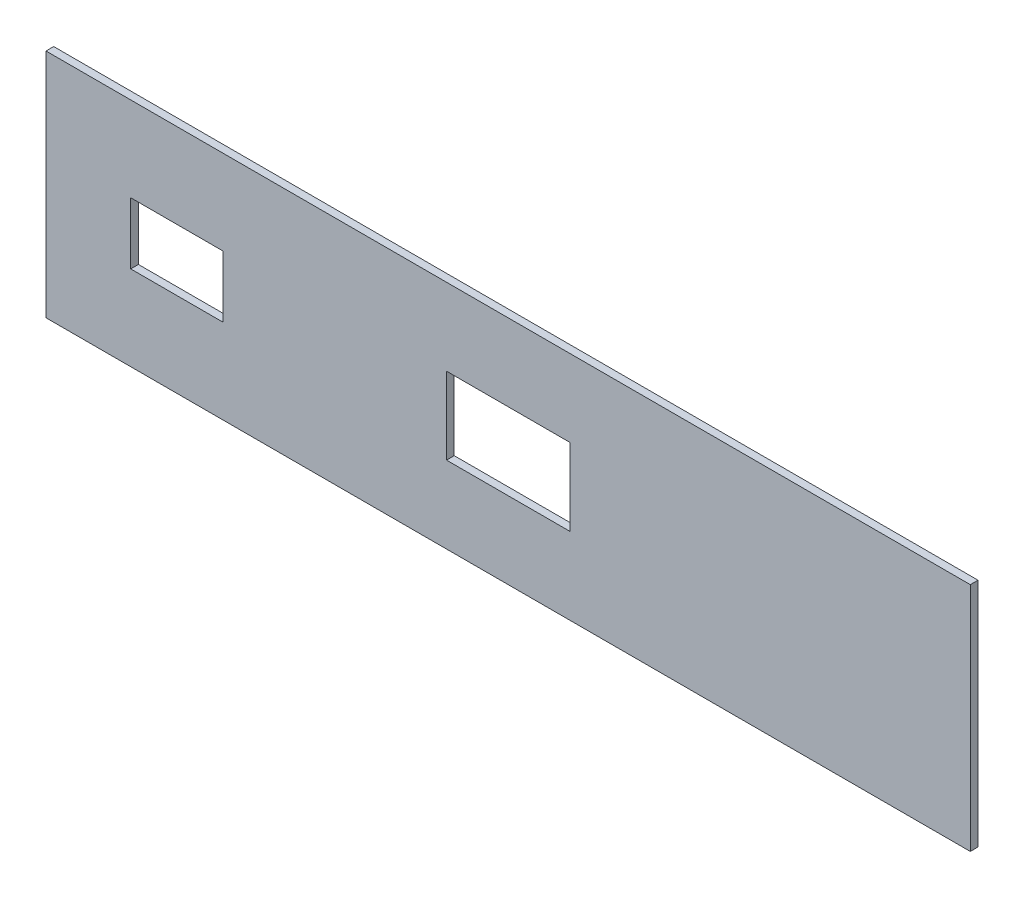
from build123d import *

# Parameters (mm, degrees)
SKETCH1_W           = 600
SKETCH1_H           = 150
SKETCH1_W_2         = 60
SKETCH1_H_2         = 40
SKETCH1_W_3         = 80
SKETCH1_H_3         = 50
BOSS_EXTRUDE1_DEPTH = 5


with BuildPart() as part:
    # Sketch1 → Boss-Extrude1 (new body)
    with BuildSketch(Plane.XY):
        Rectangle(SKETCH1_W, SKETCH1_H)
        with Locations((-215, 0)):
            Rectangle(SKETCH1_W_2, SKETCH1_H_2, mode=Mode.SUBTRACT)
        Rectangle(SKETCH1_W_3, SKETCH1_H_3, mode=Mode.SUBTRACT)
    extrude(amount=BOSS_EXTRUDE1_DEPTH)


solid = part.part
